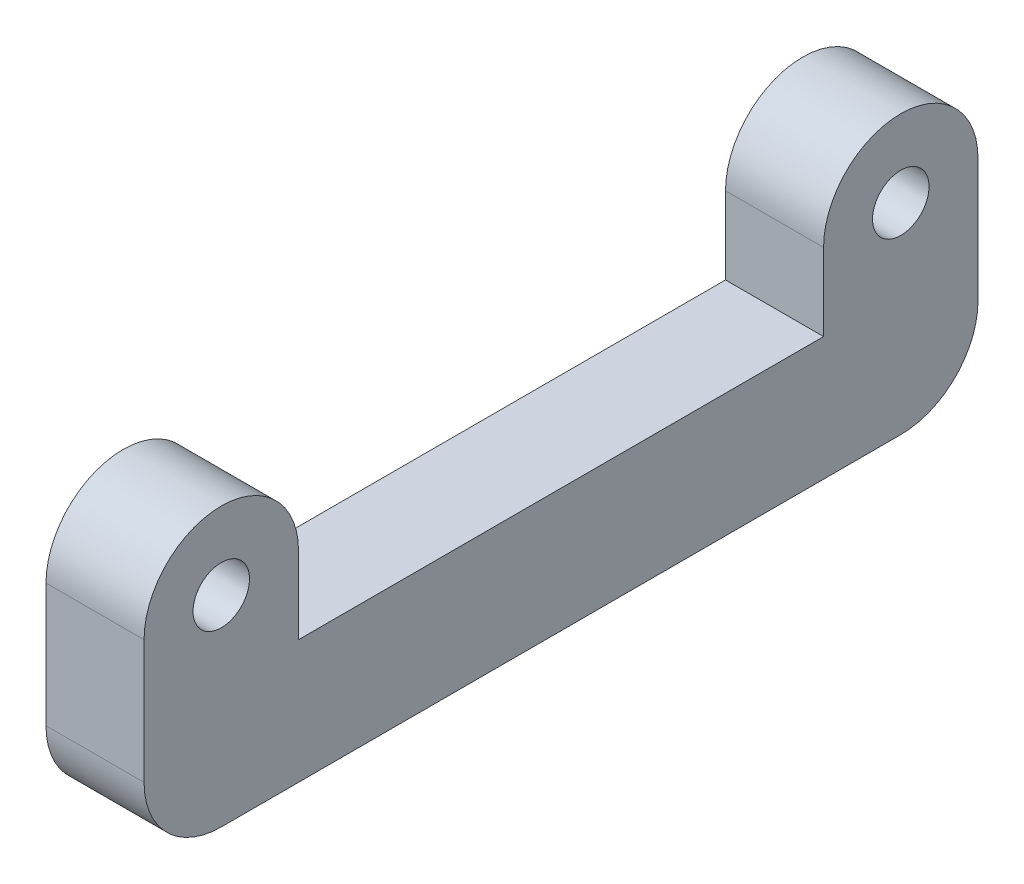
from build123d import *

# Parameters (mm, degrees)
BOSS_EXTRUDE1_DEPTH   = 6.35
FILLET1_R             = 5
F_6_CLEARANCE_HOLE1_D = 3.6576


with BuildPart() as part:
    # Sketch1 → Boss-Extrude1 (new body)
    with BuildSketch(Plane(origin=(0, 0, 0), x_dir=(0, 0, -1), z_dir=(1, 0, 0))):
        with BuildLine():
            Line((-27, -4), (-27, 4))
            Line((-27, 4), (-27, 9))
            ThreePointArc((-27, 9), (-22, 14), (-17, 9))
            Line((-17, 9), (-17, 4))
            Line((-17, 4), (17, 4))
            Line((17, 4), (17, 9))
            ThreePointArc((17, 9), (22, 14), (27, 9))
            Line((27, 9), (27, 4))
            Line((27, 4), (27, -4))
            Line((27, -4), (-27, -4))
        make_face()
    extrude(amount=BOSS_EXTRUDE1_DEPTH)

    # Fillet1
    fillet1_edges = [part.edges().sort_by_distance(p)[0] for p in [
        (3.175, -4, -27),
        (3.175, -4, 27),
    ]]
    fillet(fillet1_edges, radius=FILLET1_R)

    # #6 Clearance Hole1 (through all)
    with Locations(Plane.ZY):
        with Locations((-22, 9), (22, 9)):
            Hole(F_6_CLEARANCE_HOLE1_D / 2)


solid = part.part
